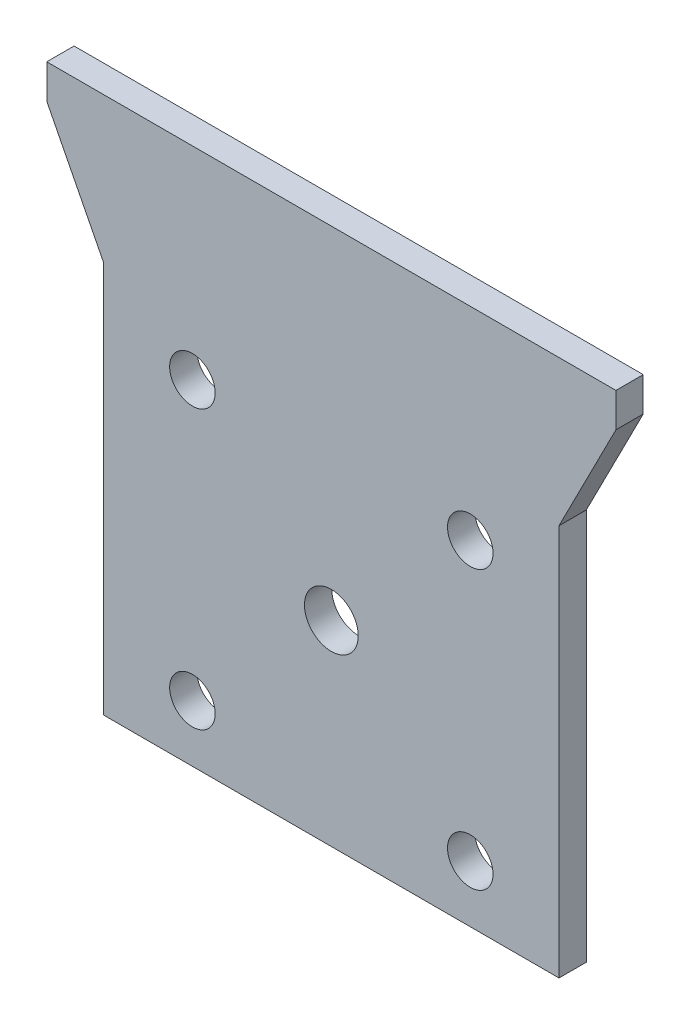
from build123d import *

# Parameters (mm, degrees)
SKETCH1_R           = 2.54
SKETCH1_R_2         = 3
BOSS_EXTRUDE1_DEPTH = 3.048


with BuildPart() as part:
    # Sketch1 → Boss-Extrude1 (new body)
    with BuildSketch(Plane.XY):
        Polygon((-25.4, -21.85), (25.4, -21.85), (25.4, 21.85), (31.75, 34.29), (31.75, 38.1), (-31.75, 38.1), (-31.75, 34.29), (-25.4, 21.85), align=None)
        with Locations((-15.5, 15.5)):
            Circle(SKETCH1_R, mode=Mode.SUBTRACT)
        with Locations((15.5, 15.5)):
            Circle(SKETCH1_R, mode=Mode.SUBTRACT)
        with Locations((15.5, -15.5)):
            Circle(SKETCH1_R, mode=Mode.SUBTRACT)
        with Locations((-15.5, -15.5)):
            Circle(SKETCH1_R, mode=Mode.SUBTRACT)
        Circle(SKETCH1_R_2, mode=Mode.SUBTRACT)
    extrude(amount=BOSS_EXTRUDE1_DEPTH)


solid = part.part
